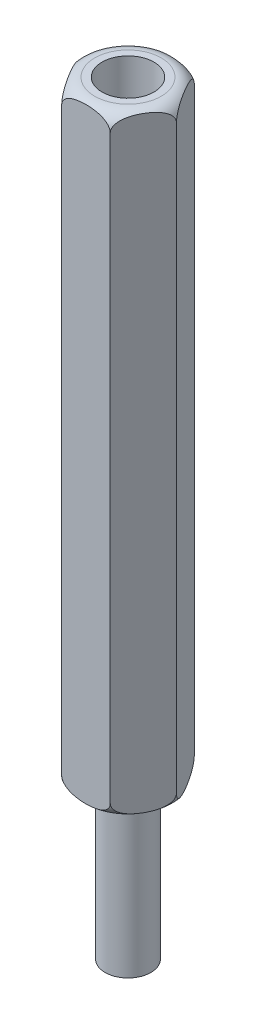
from build123d import *

# Parameters (mm, degrees)
BOSS_EXTRUDE1_DEPTH      = 40
M3_CLEARANCE_HOLE1_D     = 3.4
M3_CLEARANCE_HOLE1_DEPTH = 12
M3_CLEARANCE_HOLE1_TIP   = 1.021463052
SKETCH5_R                = 1.5
BOSS_EXTRUDE2_DEPTH      = 10


with BuildPart() as part:
    # Sketch1 → Boss-Extrude1 (new body)
    with BuildSketch(Plane(origin=(0, 0, 0), x_dir=(1, 0, 0), z_dir=(0, 1, 0))):
        Polygon((3.175426481, 0), (1.58771324, 2.75), (-1.58771324, 2.75), (-3.175426481, 0), (-1.58771324, -2.75), (1.58771324, -2.75), align=None)
    extrude(amount=BOSS_EXTRUDE1_DEPTH)

    # M3 Clearance Hole1
    with Locations(Plane(origin=(0, 40, 0), x_dir=(-1, 0, 0), z_dir=(0, 1, 0))):
        with Locations((0, 0)):
            Hole(M3_CLEARANCE_HOLE1_D / 2, depth=M3_CLEARANCE_HOLE1_DEPTH)
            with Locations((0, 0, -(M3_CLEARANCE_HOLE1_DEPTH + M3_CLEARANCE_HOLE1_TIP / 2))):  # 118° drill point
                Cone(0, M3_CLEARANCE_HOLE1_D / 2, M3_CLEARANCE_HOLE1_TIP, mode=Mode.SUBTRACT)

    # Sketch4 → Cut-Revolve1 (revolve, cut)
    with BuildSketch(Plane.XY):
        with BuildLine():
            Line((-2.175426481, 40), (-3.175426481, 40))
            Line((-3.175426481, 40), (-3.175426481, 39))
            ThreePointArc((-3.175426481, 39), (-2.882533262, 39.707106781), (-2.175426481, 40))
        make_face()
        with BuildLine():
            Line((-3.175426481, 1), (-3.175426481, 0))
            Line((-3.175426481, 0), (-2.175426481, 0))
            ThreePointArc((-2.175426481, 0), (-2.882533262, 0.292893219), (-3.175426481, 1))
        make_face()
    revolve(axis=Axis((0, 40, 0), (0, -1, 0)), mode=Mode.SUBTRACT)

    # Sketch5 → Boss-Extrude2 (add)
    with BuildSketch(Plane.XZ):
        Circle(SKETCH5_R)
    extrude(amount=BOSS_EXTRUDE2_DEPTH)


solid = part.part
